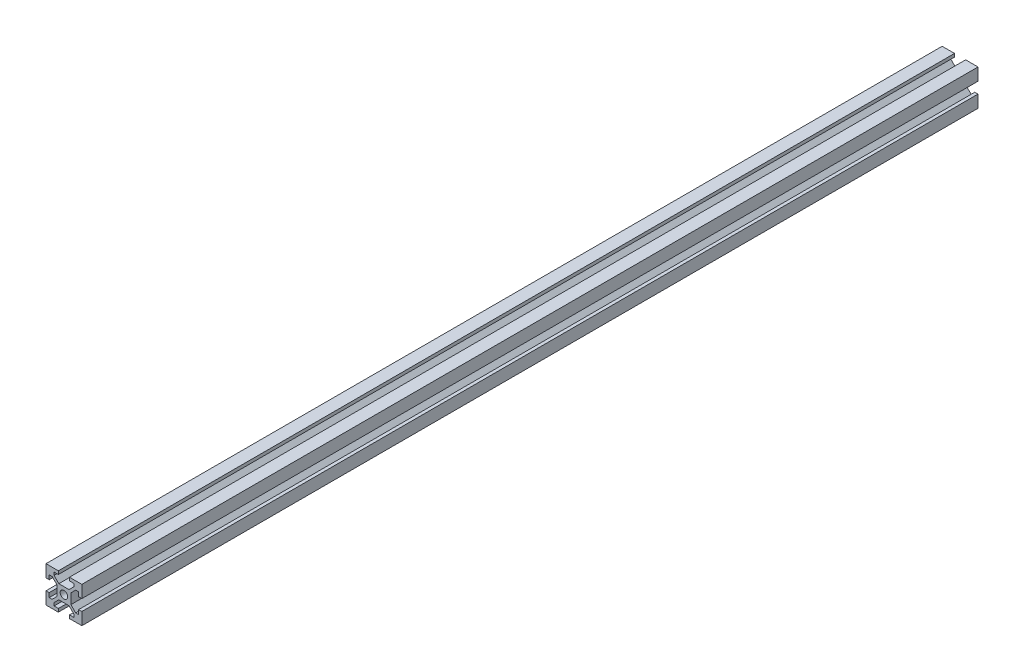
from build123d import *

# Parameters (mm, degrees)
BOSS_EXTRUDE1_DEPTH = 500
SKETCH2_R           = 2.1
CUT_EXTRUDE1_DEPTH  = 501
SKETCH3_R           = 2.1
CUT_EXTRUDE2_DEPTH  = 14.900660172


with BuildPart() as part:
    # Sketch1 → Boss-Extrude1 (new body)
    with BuildSketch(Plane.XY):
        Polygon((-3.1, 10), (-3.1, 8.200660172), (-5.5, 8.200660172), (-5.5, 6.560660172), (-2.84, 3.900660172), (2.84, 3.900660172), (5.5, 6.560660172), (5.5, 8.200660172), (3.1, 8.200660172), (3.1, 10), (10, 10), (10, 3.1), (8.200660172, 3.1), (8.200660172, 5.5), (6.560660172, 5.5), (3.900660172, 2.84), (3.900660172, -2.84), (6.560660172, -5.5), (8.200660172, -5.5), (8.200660172, -3.1), (10, -3.1), (10, -10), (3.1, -10), (3.1, -8.200660172), (5.5, -8.200660172), (5.5, -6.560660172), (2.84, -3.900660172), (-2.84, -3.900660172), (-5.5, -6.560660172), (-5.5, -8.200660172), (-3.1, -8.200660172), (-3.1, -10), (-10, -10), (-10, -3.1), (-8.200660172, -3.1), (-8.200660172, -5.5), (-6.560660172, -5.5), (-3.900660172, -2.84), (-3.900660172, 2.84), (-6.560660172, 5.5), (-8.200660172, 5.5), (-8.200660172, 3.1), (-10, 3.1), (-10, 10), align=None)
    extrude(amount=BOSS_EXTRUDE1_DEPTH)

    # Sketch2 → Cut-Extrude1 (cut, through all)
    with BuildSketch(Plane.XY.offset(500)):
        Circle(SKETCH2_R)
    extrude(amount=-CUT_EXTRUDE1_DEPTH, mode=Mode.SUBTRACT)

    # Sketch3 → Cut-Extrude2 (cut, through all)
    with BuildSketch(Plane(origin=(0, 3.900660172, 0), x_dir=(1, 0, 0), z_dir=(0, 1, 0))):
        with Locations((0, -250)):
            Circle(SKETCH3_R)
    extrude(amount=-CUT_EXTRUDE2_DEPTH, mode=Mode.SUBTRACT)


solid = part.part
